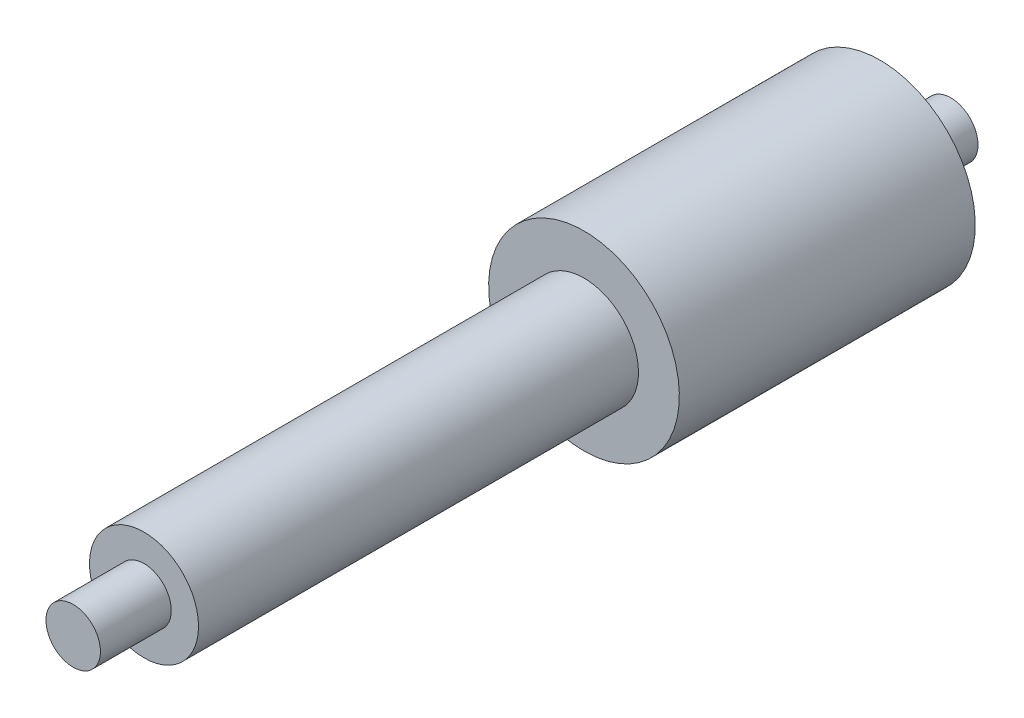
from build123d import *

# Parameters (mm, degrees)
EXTRUDE_START   = 3.386462
SKETCH_1_R      = 2
EXTRUDE_1_DEPTH = 27.013538
SKETCH_2_R      = 1
EXTRUDE_2_DEPTH = 2.6
SKETCH_4_R      = 1
EXTRUDE_3_DEPTH = 2.6
EXTRUDE_START_2 = -10.863538
SKETCH_6_R      = 3.5
EXTRUDE_5_DEPTH = 10.863538


with BuildPart() as part:
    # Эскиз1 → Бобышка-Вытянуть1 (new body)
    with BuildSketch(Plane.XY.offset(EXTRUDE_START)):
        Circle(SKETCH_1_R)
    extrude(amount=EXTRUDE_1_DEPTH)

    # Эскиз2 → Бобышка-Вытянуть2 (add)
    with BuildSketch(Plane.XY.offset(30.4)):
        Circle(SKETCH_2_R)
    extrude(amount=EXTRUDE_2_DEPTH)

    # Эскиз4 → Бобышка-Вытянуть3 (add)
    with BuildSketch(Plane(origin=(0, 0, 3.386462289), x_dir=(-1, 0, 0), z_dir=(0, 0, -1))):
        Circle(SKETCH_4_R)
    extrude(amount=EXTRUDE_3_DEPTH)

    # Эскиз6 → Бобышка-Вытянуть5 (add)
    with BuildSketch(Plane(origin=(0, 0, 3.386462289), x_dir=(-1, 0, 0), z_dir=(0, 0, -1)).offset(EXTRUDE_START_2)):
        Circle(SKETCH_6_R)
    extrude(amount=EXTRUDE_5_DEPTH)


solid = part.part
